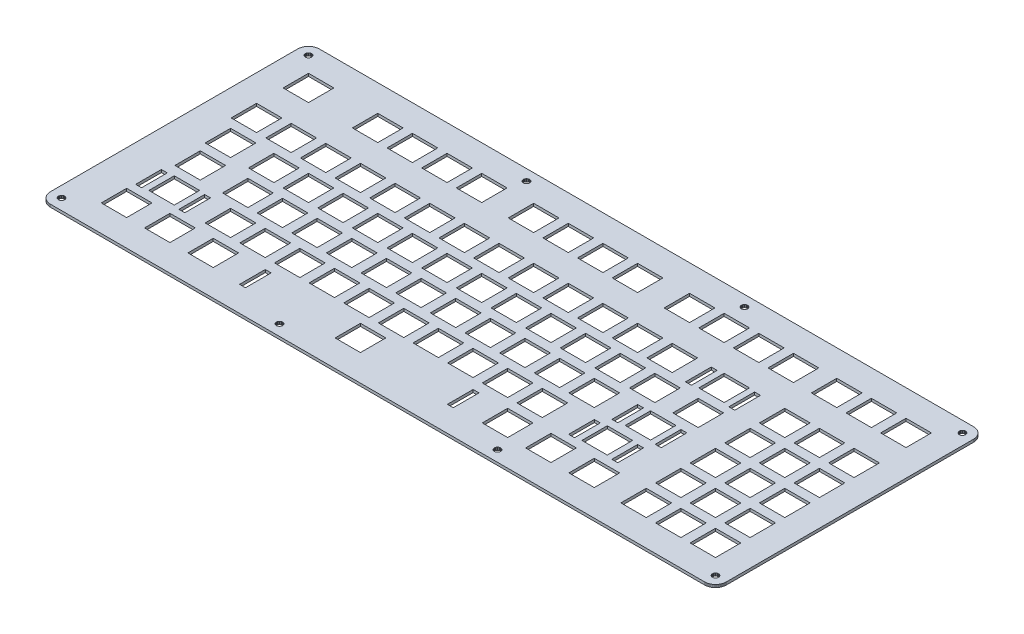
from build123d import *

# Parameters (mm, degrees)
SKETCH2_W           = 3.2495
SKETCH2_H           = 14.1497
SKETCH2_W_2         = 3.25
SKETCH2_W_3         = 13.9499
SKETCH2_H_2         = 13.9499
SKETCH2_W_4         = 13.95
SKETCH2_W_5         = 13.951
SKETCH2_H_3         = 14.1484
SKETCH2_W_6         = 3.2494
SKETCH2_W_7         = 3.249
SKETCH2_W_8         = 13.9498
SKETCH2_W_9         = 13.9503
SKETCH2_H_4         = 14.1485
SKETCH2_H_5         = 14.1503
SKETCH2_W_10        = 3.251
SKETCH2_H_6         = 13.9502
SKETCH2_H_7         = 13.95
BOSS_EXTRUDE1_DEPTH = 1.5


with BuildPart() as part:
    # Sketch2 → Boss-Extrude1 (new body)
    with BuildSketch(Plane(origin=(0, 0, 0), x_dir=(1, 0, 0), z_dir=(0, 1, 0))):
        Polygon((365.806, 147.967), (366.279, 147.949), (366.748, 147.894), (367.21, 147.803), (367.661, 147.675), (368.106, 147.511), (368.533, 147.314), (368.942, 147.085), (369.334, 146.822), (369.704, 146.529), (370.05, 146.21), (370.371, 145.865), (370.664, 145.495), (370.925, 145.102), (371.154, 144.691), (371.352, 144.264), (371.514, 143.822), (371.641, 143.368), (371.733, 142.907), (371.789, 142.44), (371.807, 141.967), (371.807, 6.09092), (371.789, 5.62102), (371.733, 5.15387), (371.641, 4.69085), (371.514, 4.23746), (371.352, 3.79511), (371.154, 3.36793), (370.925, 2.95727), (370.664, 2.56453), (370.371, 2.19659), (370.05, 1.84933), (369.704, 1.52962), (369.334, 1.23748), (368.942, 0.975653), (368.533, 0.745518), (368.106, 0.549836), (367.661, 0.385851), (367.21, 0.257693), (366.748, 0.165365), (366.279, 0.110243), (365.806, 0.0909507), (6.09505, 0.0909507), (5.62377, 0.110243), (5.15525, 0.165365), (4.6936, 0.257693), (4.24021, 0.385851), (3.79786, 0.549836), (3.37068, 0.745518), (2.96003, 0.975653), (2.56728, 1.23748), (2.19797, 1.52962), (1.85208, 1.84933), (1.53238, 2.19659), (1.24024, 2.56453), (0.978408, 2.95727), (0.748273, 3.36793), (0.551215, 3.79511), (0.38723, 4.23746), (0.259071, 4.69085), (0.168121, 5.15387), (0.112999, 5.62102), (0.0937066, 6.0923), (0.0950846, 141.967), (0.112999, 142.44), (0.168121, 142.907), (0.259071, 143.368), (0.38723, 143.822), (0.551215, 144.264), (0.748273, 144.691), (0.978408, 145.102), (1.24024, 145.495), (1.53238, 145.865), (1.85208, 146.21), (2.19797, 146.529), (2.56728, 146.822), (2.96003, 147.085), (3.37068, 147.314), (3.79786, 147.511), (4.24021, 147.675), (4.6936, 147.803), (5.15525, 147.894), (5.62377, 147.949), (6.09505, 147.968), align=None)
        Polygon((365.252, 7.75698), (364.769, 7.5117), (364.388, 7.12996), (364.141, 6.65043), (364.06, 6.11572), (364.141, 5.5838), (364.388, 5.10286), (364.769, 4.72115), (365.252, 4.47587), (365.781, 4.3918), (366.317, 4.47587), (366.797, 4.72115), (367.178, 5.10286), (367.425, 5.5838), (367.506, 6.11572), (367.425, 6.65043), (367.178, 7.12996), (366.797, 7.5117), (366.317, 7.75698), (365.781, 7.84105), align=None, mode=Mode.SUBTRACT)
        Polygon((245.361, 7.75698), (244.88, 7.5117), (244.5, 7.12996), (244.255, 6.65043), (244.169, 6.11572), (244.255, 5.5838), (244.5, 5.10286), (244.88, 4.72115), (245.361, 4.47587), (245.894, 4.3918), (246.428, 4.47587), (246.908, 4.72115), (247.29, 5.10286), (247.536, 5.5838), (247.62, 6.11572), (247.536, 6.65043), (247.29, 7.12996), (246.908, 7.5117), (246.428, 7.75698), (245.894, 7.84105), align=None, mode=Mode.SUBTRACT)
        Polygon((125.473, 7.75698), (124.992, 7.5117), (124.612, 7.12996), (124.365, 6.65043), (124.281, 6.11572), (124.365, 5.5838), (124.612, 5.10286), (124.992, 4.72115), (125.473, 4.47587), (126.007, 4.3918), (126.54, 4.47587), (127.021, 4.72115), (127.403, 5.10286), (127.648, 5.5838), (127.732, 6.11572), (127.648, 6.65043), (127.403, 7.12996), (127.021, 7.5117), (126.54, 7.75698), (126.007, 7.84105), align=None, mode=Mode.SUBTRACT)
        Polygon((5.58518, 7.75698), (5.10565, 7.5117), (4.72391, 7.12996), (4.47862, 6.65043), (4.39318, 6.11572), (4.47862, 5.5838), (4.72391, 5.10286), (5.10565, 4.72115), (5.58518, 4.47587), (6.11851, 4.3918), (6.65318, 4.47587), (7.13274, 4.72115), (7.51445, 5.10286), (7.75974, 5.5838), (7.8438, 6.11572), (7.75974, 6.65043), (7.51445, 7.12996), (7.13274, 7.5117), (6.65318, 7.75698), (6.11851, 7.84105), align=None, mode=Mode.SUBTRACT)
        with Locations((97.84485, 20.99305)):
            Rectangle(SKETCH2_W, SKETCH2_H, mode=Mode.SUBTRACT)
        with Locations((212.145, 20.99305)):
            Rectangle(SKETCH2_W_2, SKETCH2_H, mode=Mode.SUBTRACT)
        with Locations((26.40665, 21.64275)):
            Rectangle(SKETCH2_W_3, SKETCH2_H_2, mode=Mode.SUBTRACT)
        with Locations((50.21915, 21.64275)):
            Rectangle(SKETCH2_W_3, SKETCH2_H_2, mode=Mode.SUBTRACT)
        with Locations((74.03165, 21.64275)):
            Rectangle(SKETCH2_W_3, SKETCH2_H_2, mode=Mode.SUBTRACT)
        with Locations((154.994, 21.64275)):
            Rectangle(SKETCH2_W_4, SKETCH2_H_2, mode=Mode.SUBTRACT)
        with Locations((235.957, 21.64275)):
            Rectangle(SKETCH2_W_4, SKETCH2_H_2, mode=Mode.SUBTRACT)
        with Locations((259.769, 21.64275)):
            Rectangle(SKETCH2_W_4, SKETCH2_H_2, mode=Mode.SUBTRACT)
        with Locations((283.582, 21.64275)):
            Rectangle(SKETCH2_W_4, SKETCH2_H_2, mode=Mode.SUBTRACT)
        with Locations((312.157, 21.64275)):
            Rectangle(SKETCH2_W_4, SKETCH2_H_2, mode=Mode.SUBTRACT)
        with Locations((331.207, 21.64275)):
            Rectangle(SKETCH2_W_4, SKETCH2_H_2, mode=Mode.SUBTRACT)
        with Locations((350.2575, 21.64275)):
            Rectangle(SKETCH2_W_5, SKETCH2_H_2, mode=Mode.SUBTRACT)
        with Locations((21.65035, 40.0424)):
            Rectangle(SKETCH2_W, SKETCH2_H_3, mode=Mode.SUBTRACT)
        with Locations((45.4503, 40.0424)):
            Rectangle(SKETCH2_W_6, SKETCH2_H_3, mode=Mode.SUBTRACT)
        with Locations((259.7755, 40.0424)):
            Rectangle(SKETCH2_W_7, SKETCH2_H_3, mode=Mode.SUBTRACT)
        with Locations((283.5755, 40.0424)):
            Rectangle(SKETCH2_W_7, SKETCH2_H_3, mode=Mode.SUBTRACT)
        with Locations((33.5504, 40.69275)):
            Rectangle(SKETCH2_W_8, SKETCH2_H_2, mode=Mode.SUBTRACT)
        with Locations((64.50665, 40.69275)):
            Rectangle(SKETCH2_W_3, SKETCH2_H_2, mode=Mode.SUBTRACT)
        with Locations((83.55665, 40.69275)):
            Rectangle(SKETCH2_W_3, SKETCH2_H_2, mode=Mode.SUBTRACT)
        with Locations((102.60685, 40.69275)):
            Rectangle(SKETCH2_W_9, SKETCH2_H_2, mode=Mode.SUBTRACT)
        with Locations((121.657, 40.69275)):
            Rectangle(SKETCH2_W_4, SKETCH2_H_2, mode=Mode.SUBTRACT)
        with Locations((140.707, 40.69275)):
            Rectangle(SKETCH2_W_4, SKETCH2_H_2, mode=Mode.SUBTRACT)
        with Locations((159.757, 40.69275)):
            Rectangle(SKETCH2_W_4, SKETCH2_H_2, mode=Mode.SUBTRACT)
        with Locations((178.807, 40.69275)):
            Rectangle(SKETCH2_W_4, SKETCH2_H_2, mode=Mode.SUBTRACT)
        with Locations((197.857, 40.69275)):
            Rectangle(SKETCH2_W_4, SKETCH2_H_2, mode=Mode.SUBTRACT)
        with Locations((216.907, 40.69275)):
            Rectangle(SKETCH2_W_4, SKETCH2_H_2, mode=Mode.SUBTRACT)
        with Locations((235.957, 40.69275)):
            Rectangle(SKETCH2_W_4, SKETCH2_H_2, mode=Mode.SUBTRACT)
        with Locations((271.675, 40.69275)):
            Rectangle(SKETCH2_W_4, SKETCH2_H_2, mode=Mode.SUBTRACT)
        with Locations((312.157, 40.69275)):
            Rectangle(SKETCH2_W_4, SKETCH2_H_2, mode=Mode.SUBTRACT)
        with Locations((331.207, 40.69275)):
            Rectangle(SKETCH2_W_4, SKETCH2_H_2, mode=Mode.SUBTRACT)
        with Locations((350.2575, 40.69275)):
            Rectangle(SKETCH2_W_5, SKETCH2_H_2, mode=Mode.SUBTRACT)
        with Locations((264.538, 59.09235)):
            Rectangle(SKETCH2_W_2, SKETCH2_H_4, mode=Mode.SUBTRACT)
        with Locations((288.338, 59.09235)):
            Rectangle(SKETCH2_W_2, SKETCH2_H_4, mode=Mode.SUBTRACT)
        with Locations((28.7879, 59.74275)):
            Rectangle(SKETCH2_W_8, SKETCH2_H_2, mode=Mode.SUBTRACT)
        with Locations((54.98165, 59.74275)):
            Rectangle(SKETCH2_W_3, SKETCH2_H_2, mode=Mode.SUBTRACT)
        with Locations((74.03165, 59.74275)):
            Rectangle(SKETCH2_W_3, SKETCH2_H_2, mode=Mode.SUBTRACT)
        with Locations((93.08185, 59.74275)):
            Rectangle(SKETCH2_W_9, SKETCH2_H_2, mode=Mode.SUBTRACT)
        with Locations((112.132, 59.74275)):
            Rectangle(SKETCH2_W_4, SKETCH2_H_2, mode=Mode.SUBTRACT)
        with Locations((131.182, 59.74275)):
            Rectangle(SKETCH2_W_4, SKETCH2_H_2, mode=Mode.SUBTRACT)
        with Locations((150.232, 59.74275)):
            Rectangle(SKETCH2_W_4, SKETCH2_H_2, mode=Mode.SUBTRACT)
        with Locations((169.282, 59.74275)):
            Rectangle(SKETCH2_W_4, SKETCH2_H_2, mode=Mode.SUBTRACT)
        with Locations((188.332, 59.74275)):
            Rectangle(SKETCH2_W_4, SKETCH2_H_2, mode=Mode.SUBTRACT)
        with Locations((207.382, 59.74275)):
            Rectangle(SKETCH2_W_4, SKETCH2_H_2, mode=Mode.SUBTRACT)
        with Locations((226.432, 59.74275)):
            Rectangle(SKETCH2_W_4, SKETCH2_H_2, mode=Mode.SUBTRACT)
        with Locations((245.482, 59.74275)):
            Rectangle(SKETCH2_W_4, SKETCH2_H_2, mode=Mode.SUBTRACT)
        with Locations((276.438, 59.74275)):
            Rectangle(SKETCH2_W_4, SKETCH2_H_2, mode=Mode.SUBTRACT)
        with Locations((312.157, 59.74275)):
            Rectangle(SKETCH2_W_4, SKETCH2_H_2, mode=Mode.SUBTRACT)
        with Locations((331.207, 59.74275)):
            Rectangle(SKETCH2_W_4, SKETCH2_H_2, mode=Mode.SUBTRACT)
        with Locations((350.2575, 59.74275)):
            Rectangle(SKETCH2_W_5, SKETCH2_H_2, mode=Mode.SUBTRACT)
        with Locations((26.40665, 78.79275)):
            Rectangle(SKETCH2_W_3, SKETCH2_H_2, mode=Mode.SUBTRACT)
        with Locations((50.21915, 78.79275)):
            Rectangle(SKETCH2_W_3, SKETCH2_H_2, mode=Mode.SUBTRACT)
        with Locations((69.26915, 78.79275)):
            Rectangle(SKETCH2_W_3, SKETCH2_H_2, mode=Mode.SUBTRACT)
        with Locations((88.31915, 78.79275)):
            Rectangle(SKETCH2_W_3, SKETCH2_H_2, mode=Mode.SUBTRACT)
        with Locations((107.369, 78.79275)):
            Rectangle(SKETCH2_W_4, SKETCH2_H_2, mode=Mode.SUBTRACT)
        with Locations((126.419, 78.79275)):
            Rectangle(SKETCH2_W_4, SKETCH2_H_2, mode=Mode.SUBTRACT)
        with Locations((145.469, 78.79275)):
            Rectangle(SKETCH2_W_4, SKETCH2_H_2, mode=Mode.SUBTRACT)
        with Locations((164.519, 78.79275)):
            Rectangle(SKETCH2_W_4, SKETCH2_H_2, mode=Mode.SUBTRACT)
        with Locations((183.569, 78.79275)):
            Rectangle(SKETCH2_W_4, SKETCH2_H_2, mode=Mode.SUBTRACT)
        with Locations((202.619, 78.79275)):
            Rectangle(SKETCH2_W_4, SKETCH2_H_2, mode=Mode.SUBTRACT)
        with Locations((221.669, 78.79275)):
            Rectangle(SKETCH2_W_4, SKETCH2_H_2, mode=Mode.SUBTRACT)
        with Locations((240.719, 78.79275)):
            Rectangle(SKETCH2_W_4, SKETCH2_H_2, mode=Mode.SUBTRACT)
        with Locations((259.769, 78.79275)):
            Rectangle(SKETCH2_W_4, SKETCH2_H_2, mode=Mode.SUBTRACT)
        with Locations((283.582, 78.79275)):
            Rectangle(SKETCH2_W_4, SKETCH2_H_2, mode=Mode.SUBTRACT)
        with Locations((312.157, 78.79275)):
            Rectangle(SKETCH2_W_4, SKETCH2_H_2, mode=Mode.SUBTRACT)
        with Locations((331.207, 78.79275)):
            Rectangle(SKETCH2_W_4, SKETCH2_H_2, mode=Mode.SUBTRACT)
        with Locations((350.2575, 78.79275)):
            Rectangle(SKETCH2_W_5, SKETCH2_H_2, mode=Mode.SUBTRACT)
        with Locations((266.92, 97.19185)):
            Rectangle(SKETCH2_W_2, SKETCH2_H_5, mode=Mode.SUBTRACT)
        with Locations((290.7195, 97.19185)):
            Rectangle(SKETCH2_W_10, SKETCH2_H_5, mode=Mode.SUBTRACT)
        with Locations((21.64415, 97.8429)):
            Rectangle(SKETCH2_W_3, SKETCH2_H_6, mode=Mode.SUBTRACT)
        with Locations((40.69415, 97.8429)):
            Rectangle(SKETCH2_W_3, SKETCH2_H_6, mode=Mode.SUBTRACT)
        with Locations((59.74415, 97.8429)):
            Rectangle(SKETCH2_W_3, SKETCH2_H_6, mode=Mode.SUBTRACT)
        with Locations((78.79415, 97.8429)):
            Rectangle(SKETCH2_W_3, SKETCH2_H_6, mode=Mode.SUBTRACT)
        with Locations((97.8441, 97.8429)):
            Rectangle(SKETCH2_W_8, SKETCH2_H_6, mode=Mode.SUBTRACT)
        with Locations((116.894, 97.8429)):
            Rectangle(SKETCH2_W_4, SKETCH2_H_6, mode=Mode.SUBTRACT)
        with Locations((135.944, 97.8429)):
            Rectangle(SKETCH2_W_4, SKETCH2_H_6, mode=Mode.SUBTRACT)
        with Locations((154.994, 97.8429)):
            Rectangle(SKETCH2_W_4, SKETCH2_H_6, mode=Mode.SUBTRACT)
        with Locations((174.044, 97.8429)):
            Rectangle(SKETCH2_W_4, SKETCH2_H_6, mode=Mode.SUBTRACT)
        with Locations((193.094, 97.8429)):
            Rectangle(SKETCH2_W_4, SKETCH2_H_6, mode=Mode.SUBTRACT)
        with Locations((212.144, 97.8429)):
            Rectangle(SKETCH2_W_4, SKETCH2_H_6, mode=Mode.SUBTRACT)
        with Locations((231.194, 97.8429)):
            Rectangle(SKETCH2_W_4, SKETCH2_H_6, mode=Mode.SUBTRACT)
        with Locations((250.244, 97.8429)):
            Rectangle(SKETCH2_W_4, SKETCH2_H_6, mode=Mode.SUBTRACT)
        with Locations((278.819, 97.8429)):
            Rectangle(SKETCH2_W_4, SKETCH2_H_6, mode=Mode.SUBTRACT)
        with Locations((312.157, 97.8429)):
            Rectangle(SKETCH2_W_4, SKETCH2_H_6, mode=Mode.SUBTRACT)
        with Locations((331.207, 97.8429)):
            Rectangle(SKETCH2_W_4, SKETCH2_H_6, mode=Mode.SUBTRACT)
        with Locations((350.2575, 97.8429)):
            Rectangle(SKETCH2_W_5, SKETCH2_H_6, mode=Mode.SUBTRACT)
        with Locations((21.64415, 126.418)):
            Rectangle(SKETCH2_W_3, SKETCH2_H_7, mode=Mode.SUBTRACT)
        with Locations((59.74415, 126.418)):
            Rectangle(SKETCH2_W_3, SKETCH2_H_7, mode=Mode.SUBTRACT)
        with Locations((78.79415, 126.418)):
            Rectangle(SKETCH2_W_3, SKETCH2_H_7, mode=Mode.SUBTRACT)
        with Locations((97.8441, 126.418)):
            Rectangle(SKETCH2_W_8, SKETCH2_H_7, mode=Mode.SUBTRACT)
        with Locations((116.894, 126.418)):
            Rectangle(SKETCH2_W_4, SKETCH2_H_7, mode=Mode.SUBTRACT)
        with Locations((145.469, 126.418)):
            Rectangle(SKETCH2_W_4, SKETCH2_H_7, mode=Mode.SUBTRACT)
        with Locations((164.519, 126.418)):
            Rectangle(SKETCH2_W_4, SKETCH2_H_7, mode=Mode.SUBTRACT)
        with Locations((183.569, 126.418)):
            Rectangle(SKETCH2_W_4, SKETCH2_H_7, mode=Mode.SUBTRACT)
        with Locations((202.619, 126.418)):
            Rectangle(SKETCH2_W_4, SKETCH2_H_7, mode=Mode.SUBTRACT)
        with Locations((231.194, 126.418)):
            Rectangle(SKETCH2_W_4, SKETCH2_H_7, mode=Mode.SUBTRACT)
        with Locations((250.244, 126.418)):
            Rectangle(SKETCH2_W_4, SKETCH2_H_7, mode=Mode.SUBTRACT)
        with Locations((269.294, 126.418)):
            Rectangle(SKETCH2_W_4, SKETCH2_H_7, mode=Mode.SUBTRACT)
        with Locations((288.344, 126.418)):
            Rectangle(SKETCH2_W_4, SKETCH2_H_7, mode=Mode.SUBTRACT)
        with Locations((312.157, 126.418)):
            Rectangle(SKETCH2_W_4, SKETCH2_H_7, mode=Mode.SUBTRACT)
        with Locations((331.207, 126.418)):
            Rectangle(SKETCH2_W_4, SKETCH2_H_7, mode=Mode.SUBTRACT)
        with Locations((350.2575, 126.418)):
            Rectangle(SKETCH2_W_5, SKETCH2_H_7, mode=Mode.SUBTRACT)
        Polygon((125.473, 143.583), (124.992, 143.338), (124.612, 142.956), (124.365, 142.477), (124.281, 141.942), (124.365, 141.409), (124.612, 140.929), (124.992, 140.547), (125.473, 140.302), (126.007, 140.217), (126.54, 140.302), (127.021, 140.547), (127.403, 140.929), (127.648, 141.409), (127.732, 141.942), (127.648, 142.477), (127.403, 142.956), (127.021, 143.338), (126.54, 143.583), (126.007, 143.667), align=None, mode=Mode.SUBTRACT)
        Polygon((245.361, 143.583), (244.88, 143.338), (244.5, 142.956), (244.255, 142.477), (244.169, 141.942), (244.255, 141.409), (244.5, 140.929), (244.88, 140.547), (245.361, 140.302), (245.894, 140.217), (246.428, 140.302), (246.908, 140.547), (247.29, 140.929), (247.536, 141.409), (247.62, 141.942), (247.536, 142.477), (247.29, 142.956), (246.908, 143.338), (246.428, 143.583), (245.894, 143.667), align=None, mode=Mode.SUBTRACT)
        Polygon((365.252, 143.583), (364.769, 143.338), (364.388, 142.956), (364.141, 142.477), (364.06, 141.942), (364.141, 141.409), (364.388, 140.929), (364.769, 140.547), (365.252, 140.302), (365.781, 140.217), (366.317, 140.302), (366.797, 140.547), (367.178, 140.929), (367.425, 141.409), (367.506, 141.942), (367.425, 142.477), (367.178, 142.956), (366.797, 143.338), (366.317, 143.583), (365.781, 143.667), align=None, mode=Mode.SUBTRACT)
        Polygon((5.58518, 143.583), (5.10565, 143.338), (4.72391, 142.956), (4.47862, 142.477), (4.39318, 141.942), (4.47862, 141.409), (4.72391, 140.929), (5.10565, 140.547), (5.58518, 140.302), (6.11851, 140.217), (6.65318, 140.302), (7.13274, 140.547), (7.51445, 140.929), (7.75974, 141.409), (7.8438, 141.942), (7.75974, 142.477), (7.51445, 142.956), (7.13274, 143.338), (6.65318, 143.583), (6.11851, 143.667), align=None, mode=Mode.SUBTRACT)
    extrude(amount=BOSS_EXTRUDE1_DEPTH)


solid = part.part
